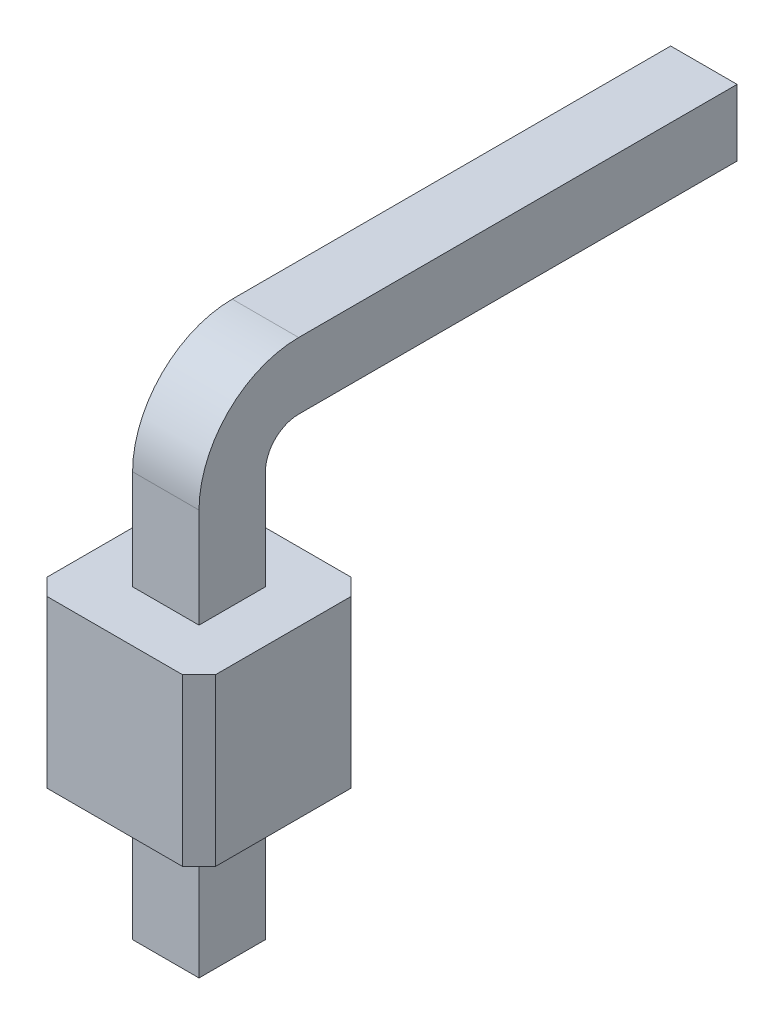
from build123d import *

# Parameters (mm, degrees)
BOSS_EXTRUDE1_DEPTH      = 2.5
EXTRUDE_THIN1_DEPTH      = 0.5
EXTRUDE_THIN1_DEPTH_BACK = 0.5
CHAMFER1_SIZE            = 0.4


with BuildPart() as part:
    # Sketch1 → Boss-Extrude1 (new body)
    with BuildSketch(Plane(origin=(0, 0, 0), x_dir=(-1, 0, 0), z_dir=(0, 1, 0))):
        Polygon((-1.02, 1.27), (1.02, 1.27), (1.27, 1.02), (1.27, -1.02), (1.02, -1.27), (-1.02, -1.27), (-1.27, -1.02), (-1.27, 1.02), align=None)
    extrude(amount=BOSS_EXTRUDE1_DEPTH)

    # Sketch2 → Extrude-Thin1 (add, two sides: drawn at the far end of the back side and taken through both)
    with BuildSketch(Plane(origin=(0, 0, 0), x_dir=(0, 0, -1), z_dir=(1, 0, 0)).offset(-EXTRUDE_THIN1_DEPTH_BACK)):
        with BuildLine():
            Line((0.5, -2.5), (0.5, 0))
            Line((0.5, 0), (0.5, 4))
            ThreePointArc((0.5, 4), (0.646446609, 4.353553391), (1, 4.5))
            Line((1, 4.5), (8, 4.5))
            Line((8, 4.5), (8, 5.5))
            Line((8, 5.5), (1, 5.5))
            ThreePointArc((1, 5.5), (-0.060660172, 5.060660172), (-0.5, 4))
            Line((-0.5, 4), (-0.5, 0))
            Line((-0.5, 0), (-0.5, -2.5))
            Line((-0.5, -2.5), (0.5, -2.5))
        make_face()
    extrude(amount=EXTRUDE_THIN1_DEPTH + EXTRUDE_THIN1_DEPTH_BACK)

    # Chamfer1
    chamfer1_edges = [part.edges().sort_by_distance(p)[0] for p in [
        (-0.5, 5, -8),
        (0, 4.5, -8),
        (0.5, 5, -8),
        (0, 5.5, -8),
        (0, -2.5, -0.5),
        (-0.5, -2.5, 0),
        (0, -2.5, 0.5),
        (0.5, -2.5, 0),
    ]]
    chamfer(chamfer1_edges, length=CHAMFER1_SIZE)


solid = part.part
